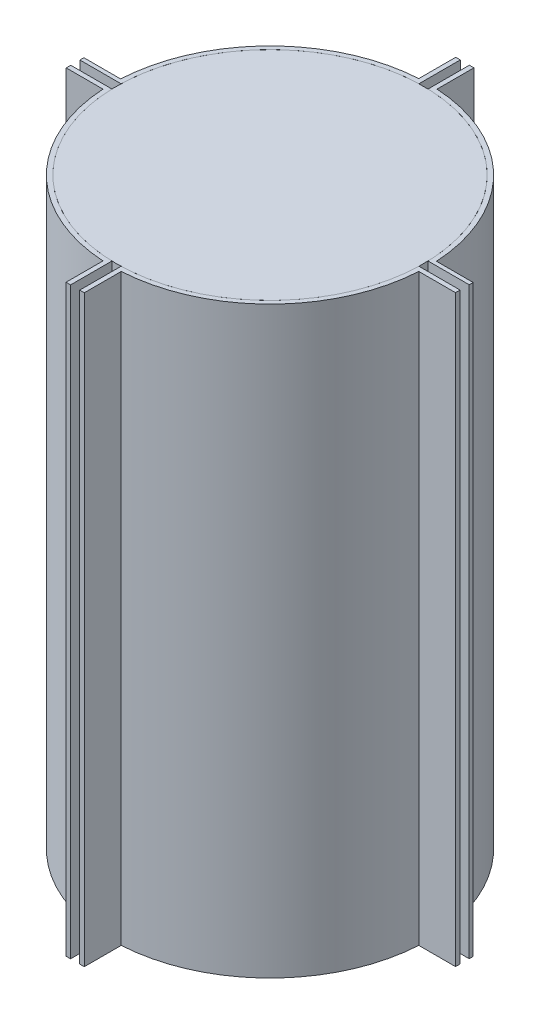
from build123d import *

# Parameters (mm, degrees)
SKETCH1_R           = 106.934
BOSS_EXTRUDE1_DEPTH = 406.4
BOSS_EXTRUDE3_DEPTH = 406.4
SKETCH3_W           = 254
SKETCH3_H           = 6.35
SKETCH3_W_2         = 6.35
SKETCH3_H_2         = 254
CUT_EXTRUDE2_DEPTH  = 407.4
BOSS_EXTRUDE5_DEPTH = 406.4


with BuildPart() as part:
    # Sketch1 → Boss-Extrude1 (new body)
    with BuildSketch(Plane(origin=(0, 0, 0), x_dir=(1, 0, 0), z_dir=(0, 1, 0))):
        Circle(SKETCH1_R)
    extrude(amount=BOSS_EXTRUDE1_DEPTH)


with BuildPart() as body_2:
    # Sketch2 → Boss-Extrude3 (new body)
    with BuildSketch(Plane(origin=(0, 0, 0), x_dir=(1, 0, 0), z_dir=(0, 1, 0))):
        with BuildLine():
            ThreePointArc((110.109, 0), (77.85882057, 77.85882057), (0, 110.109))
            ThreePointArc((0, 110.109), (-77.85882057, 77.85882057), (-110.109, 0))
            ThreePointArc((-110.109, 0), (-77.85882057, -77.85882057), (0, -110.109))
            ThreePointArc((0, -110.109), (77.85882057, -77.85882057), (110.109, 0))
        make_face()
        with BuildLine():
            ThreePointArc((106.934, 0), (75.613756539, 75.613756539), (0, 106.934))
            ThreePointArc((0, 106.934), (-75.613756539, 75.613756539), (-106.934, 0))
            ThreePointArc((-106.934, 0), (-75.613756539, -75.613756539), (0, -106.934))
            ThreePointArc((0, -106.934), (75.613756539, -75.613756539), (106.934, 0))
        make_face(mode=Mode.SUBTRACT)
    extrude(amount=BOSS_EXTRUDE3_DEPTH)

    # Sketch3 → Cut-Extrude2 (cut, through all)
    with BuildSketch(Plane(origin=(0, 0, 0), x_dir=(1, 0, 0), z_dir=(0, 1, 0))):
        Rectangle(SKETCH3_W, SKETCH3_H)
        Rectangle(SKETCH3_W_2, SKETCH3_H_2)
    extrude(amount=CUT_EXTRUDE2_DEPTH, mode=Mode.SUBTRACT)

    # Sketch5 → Boss-Extrude5 (add)
    with BuildSketch(Plane(origin=(0, 0, 0), x_dir=(1, 0, 0), z_dir=(0, 1, 0))):
        Polygon((-110.063214818, 3.175), (-135.520832556, 3.175), (-135.520832556, 5.944129876), (-108.207325928, 5.944129876), align=None)
        Polygon((-110.063214818, -3.175), (-135.520832642, -3.175), (-135.520832642, -6.35), (-108.207325928, -6.35), align=None)
        Polygon((135.520832642, -6.35), (108.207325928, -6.35), (110.063214818, -3.175), (135.520832642, -3.175), align=None)
        Polygon((135.520832556, 5.944129876), (108.207325928, 5.944129876), (110.063214818, 3.175), (135.520832556, 3.175), align=None)
        Polygon((-3.175, 110.063214818), (-3.175, 135.646128135), (-6.349518475, 135.646128135), (-6.349518475, 108.332621421), align=None)
        Polygon((6.349518475, 135.646128135), (6.349518475, 108.332621421), (3.175, 110.063214818), (3.175, 135.646128135), align=None)
        Polygon((3.175, -135.646128135), (6.349518475, -135.646128135), (6.349518475, -108.332621421), (3.175, -110.063214818), align=None)
        Polygon((-6.349518475, -135.646128135), (-6.349518475, -108.332621421), (-3.175, -110.063214818), (-3.175, -135.646128135), align=None)
    extrude(amount=BOSS_EXTRUDE5_DEPTH)


solid = Compound([part.part, body_2.part])
